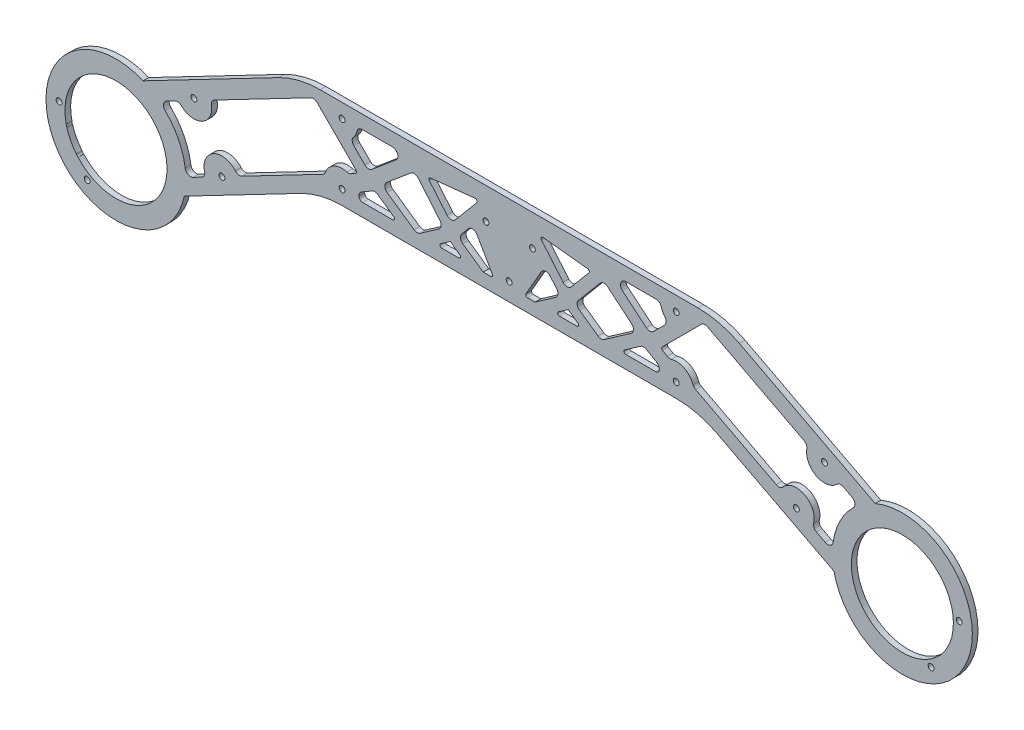
from build123d import *

# Parameters (mm, degrees)
BASE_DEPTH               = 3.175
FILLET1_R                = 10
SKETCH2_R                = 1.65
ADAPTER_ATTACHMENT_DEPTH = 4.175
SKETCH3_R                = 1.65
STRUT_HOLES_DEPTH        = 4.175
SKETCH4_R                = 16.05
SKETCH4_R_2              = 2.75
MOTOR_CONNECTION_DEPTH   = 4.175
SKETCH5_R                = 39.154759474
SKETCH5_R_2              = 28.55
SKETCH5_R_3              = 1.65
MOTOR_RING_DEPTH         = 3.175
MOTOR_SLOT_DEPTH         = 4.175
LIGHTENING_HOLES_DEPTH   = 4.175


with BuildPart() as part:
    # Sketch1 → Base (new body)
    with BuildSketch(Plane.XY):
        with BuildLine():
            Line((105.709062273, -33.213203436), (-105.709062273, -33.213203436))
            ThreePointArc((-105.709062273, -33.213203436), (-117.593356889, -34.646099945), (-128.796492935, -38.862661777))
            Line((-128.796492935, -38.862661777), (-262.589094492, -108.510681755))
            Line((-262.589094492, -108.510681755), (-239.50166383, -152.861223414))
            Line((-239.50166383, -152.861223414), (-116.561570773, -88.862661777))
            ThreePointArc((-116.561570773, -88.862661777), (-105.358434728, -84.646099945), (-93.474140111, -83.213203436))
            Line((-93.474140111, -83.213203436), (93.474140111, -83.213203436))
            ThreePointArc((93.474140111, -83.213203436), (105.358434728, -84.646099945), (116.561570773, -88.862661777))
            Line((116.561570773, -88.862661777), (239.50166383, -152.861223414))
            Line((239.50166383, -152.861223414), (262.589094492, -108.510681755))
            Line((262.589094492, -108.510681755), (128.796492935, -38.862661777))
            ThreePointArc((128.796492935, -38.862661777), (117.593356889, -34.646099945), (105.709062273, -33.213203436))
        make_face()
    extrude(amount=BASE_DEPTH)

    # Fillet1
    fillet1_edges = [part.edges().sort_by_distance(p)[0] for p in [
        (-262.589094492, -108.510681755, 1.5875),
        (262.589094492, -108.510681755, 1.5875),
        (239.50166383, -152.861223414, 1.5875),
        (-239.50166383, -152.861223414, 1.5875),
    ]]
    fillet(fillet1_edges, radius=FILLET1_R)

    # Sketch2 → Adapter Attachment (cut, through all)
    with BuildSketch(Plane.XY.offset(3.175)):
        with Locations((-12.990381057, -50.713203436)):
            Circle(SKETCH2_R)
        with Locations((12.990381057, -50.713203436)):
            Circle(SKETCH2_R)
        with Locations((0, -73.213203436)):
            Circle(SKETCH2_R)
    extrude(amount=-ADAPTER_ATTACHMENT_DEPTH, mode=Mode.SUBTRACT)

    # Sketch3 → Strut Holes (cut, through all)
    with BuildSketch(Plane.XY.offset(3.175)):
        with Locations((-251.799018921, -111.912779515)):
            Circle(SKETCH3_R)
        with Locations((-236.099566071, -142.071147843)):
            Circle(SKETCH3_R)
        with Locations((-160.703645251, -102.822515718)):
            Circle(SKETCH3_R)
        with Locations((-176.403098101, -72.66414739)):
            Circle(SKETCH3_R)
        with Locations((-93.474140111, -75.213203436)):
            Circle(SKETCH3_R)
        with Locations((-93.474140111, -41.213203436)):
            Circle(SKETCH3_R)
        with Locations((93.474140111, -41.213203436)):
            Circle(SKETCH3_R)
        with Locations((93.474140111, -75.213203436)):
            Circle(SKETCH3_R)
        with Locations((176.403098101, -72.66414739)):
            Circle(SKETCH3_R)
        with Locations((160.703645251, -102.822515718)):
            Circle(SKETCH3_R)
        with Locations((251.799018921, -111.912779515)):
            Circle(SKETCH3_R)
        with Locations((236.099566071, -142.071147843)):
            Circle(SKETCH3_R)
    extrude(amount=-STRUT_HOLES_DEPTH, mode=Mode.SUBTRACT)

    # Sketch4 → Motor Connection (cut, through all)
    with BuildSketch(Plane.XY.offset(3.175)):
        with Locations((-220, -114.524751121)):
            Circle(SKETCH4_R)
        with Locations((-241.458631392, -107.758870633)):
            Circle(SKETCH4_R_2)
        with Locations((-213.234119511, -93.06611973)):
            Circle(SKETCH4_R_2)
        with Locations((-198.541368608, -121.29063161)):
            Circle(SKETCH4_R_2)
        with Locations((-226.765880489, -135.983382513)):
            Circle(SKETCH4_R_2)
        with Locations((226.765880489, -135.983382513)):
            Circle(SKETCH4_R_2)
        with Locations((241.458631392, -107.758870633)):
            Circle(SKETCH4_R_2)
        with Locations((198.541368608, -121.29063161)):
            Circle(SKETCH4_R_2)
        with Locations((213.234119511, -93.06611973)):
            Circle(SKETCH4_R_2)
        with Locations((220, -114.524751121)):
            Circle(SKETCH4_R)
    extrude(amount=-MOTOR_CONNECTION_DEPTH, mode=Mode.SUBTRACT)

    # Sketch5 → Motor Ring (add)
    with BuildSketch(Plane.XY.offset(3.175)):
        with Locations((-220, -114.524751121)):
            Circle(SKETCH5_R)
        with Locations((-220, -114.524751121)):
            Circle(SKETCH5_R_2, mode=Mode.SUBTRACT)
        with Locations((-236.099566071, -142.071147843)):
            Circle(SKETCH5_R_3, mode=Mode.SUBTRACT)
        with Locations((-251.799018921, -111.912779515)):
            Circle(SKETCH5_R_3, mode=Mode.SUBTRACT)
        with Locations((220, -114.524751121)):
            Circle(SKETCH5_R)
        with Locations((251.799018921, -111.912779515)):
            Circle(SKETCH5_R_3, mode=Mode.SUBTRACT)
        with Locations((236.099566071, -142.071147843)):
            Circle(SKETCH5_R_3, mode=Mode.SUBTRACT)
        with Locations((220, -114.524751121)):
            Circle(SKETCH5_R_2, mode=Mode.SUBTRACT)
    extrude(amount=-MOTOR_RING_DEPTH)

    # Sketch5_2 → Motor Slot (cut, through all)
    with BuildSketch(Plane.XY.offset(3.175)):
        with BuildLine():
            ThreePointArc((-196.226386581, -130.333539975), (-192.670170481, -122.782045984), (-191.45, -114.524751121))
            ThreePointArc((-191.45, -114.524751121), (-199.570939599, -94.580930245), (-219.313817243, -85.982998316))
            Line((-219.313817243, -85.982998316), (-243.773613419, -98.715962268))
            ThreePointArc((-243.773613419, -98.715962268), (-245.324159287, -127.707674029), (-220.686182757, -143.066503927))
            Line((-220.686182757, -143.066503927), (-196.226386581, -130.333539975))
        make_face()
        with BuildLine():
            Line((243.773613419, -98.715962268), (219.313817243, -85.982998316))
            ThreePointArc((219.313817243, -85.982998316), (194.675840713, -101.341828214), (196.226386581, -130.333539975))
            Line((196.226386581, -130.333539975), (220.686182757, -143.066503927))
            ThreePointArc((220.686182757, -143.066503927), (240.429060401, -134.468571998), (248.55, -114.524751121))
            ThreePointArc((248.55, -114.524751121), (247.329829519, -106.267456259), (243.773613419, -98.715962268))
        make_face()
    extrude(amount=-MOTOR_SLOT_DEPTH, mode=Mode.SUBTRACT)

    # Sketch6 → Lightening Holes (cut, through all)
    with BuildSketch(Plane.XY.offset(3.175)):
        with BuildLine():
            Line((-247.606795008, -122.131647293), (-242.06581165, -132.775777291))
            ThreePointArc((-242.06581165, -132.775777291), (-240.893201582, -133.759713966), (-239.368292757, -133.626301731))
            Line((-239.368292757, -133.626301731), (-237.59427109, -132.702804504))
            ThreePointArc((-237.59427109, -132.702804504), (-236.610334415, -131.530194437), (-236.743746651, -130.005285612))
            Line((-236.743746651, -130.005285612), (-242.284730009, -119.361155613))
            ThreePointArc((-242.284730009, -119.361155613), (-243.457340077, -118.377218938), (-244.982248902, -118.510631174))
            Line((-244.982248902, -118.510631174), (-246.756270569, -119.4341284))
            ThreePointArc((-246.756270569, -119.4341284), (-247.740207244, -120.606738467), (-247.606795008, -122.131647293))
        make_face()
        with BuildLine():
            Line((-14.539319226, -75.963203436), (-10.271370034, -75.963203436))
            ThreePointArc((-10.271370034, -75.963203436), (-9.40534463, -75.463203436), (-9.40534463, -74.463203436))
            Line((-9.40534463, -74.463203436), (-17.992546949, -59.589732725))
            ThreePointArc((-17.992546949, -59.589732725), (-20.329155932, -58.10114863), (-22.88875649, -59.161369895))
            Line((-22.88875649, -59.161369895), (-26.574867267, -63.554305657))
            ThreePointArc((-26.574867267, -63.554305657), (-27.251068522, -65.874247063), (-25.997463246, -67.940124619))
            Line((-25.997463246, -67.940124619), (-14.539319226, -75.963203436))
        make_face()
        with BuildLine():
            Line((-28.171594802, -75.963203436), (-37.828405198, -75.963203436))
            ThreePointArc((-37.828405198, -75.963203436), (-38.782122148, -75.263909235), (-38.401981634, -74.144051391))
            Line((-38.401981634, -74.144051391), (-33, -70.36154313))
            Line((-33, -70.36154313), (-27.598018366, -74.144051391))
            ThreePointArc((-27.598018366, -74.144051391), (-27.217877852, -75.263909235), (-28.171594802, -75.963203436))
        make_face()
        with BuildLine():
            Line((-18.961528069, -42.471920461), (-43.967972264, -45.100203655))
            ThreePointArc((-43.967972264, -45.100203655), (-44.790627656, -45.720118957), (-44.629488244, -46.73751316))
            Line((-44.629488244, -46.73751316), (-34.761050762, -58.498258983))
            ThreePointArc((-34.761050762, -58.498258983), (-32.462917433, -59.569896154), (-30.164784103, -58.498258983))
            Line((-30.164784103, -58.498258983), (-18.090955162, -44.109229966))
            ThreePointArc((-18.090955162, -44.109229966), (-17.974052013, -42.996970793), (-18.961528069, -42.471920461))
        make_face()
        with BuildLine():
            Line((-50.875469734, -48.628185241), (-38.748511984, -63.080530707))
            ThreePointArc((-38.748511984, -63.080530707), (-38.072310729, -65.400472113), (-39.325916004, -67.466349669))
            Line((-39.325916004, -67.466349669), (-49.779270691, -74.785867421))
            ThreePointArc((-49.779270691, -74.785867421), (-51.5, -75.328411288), (-53.220729309, -74.785867421))
            Line((-53.220729309, -74.785867421), (-68.276972398, -64.243372513))
            ThreePointArc((-68.276972398, -64.243372513), (-69.553387753, -61.916774542), (-68.484605918, -59.487783051))
            Line((-68.484605918, -59.487783051), (-55.101965892, -48.258414741))
            ThreePointArc((-55.101965892, -48.258414741), (-52.912135835, -47.567963976), (-50.875469734, -48.628185241))
        make_face()
        with BuildLine():
            Line((-64.598018366, -74.144051391), (-73.50757862, -67.905510139))
            ThreePointArc((-73.50757862, -67.905510139), (-75.097449767, -67.365821608), (-76.728307929, -67.764890061))
            Line((-76.728307929, -67.764890061), (-82.5, -71.097178032))
            ThreePointArc((-82.5, -71.097178032), (-83.598076211, -72.195254243), (-84, -73.695254243))
            Line((-84, -73.695254243), (-84, -73.963203436))
            ThreePointArc((-84, -73.963203436), (-83.414213562, -75.377416998), (-82, -75.963203436))
            Line((-82, -75.963203436), (-65.171594802, -75.963203436))
            ThreePointArc((-65.171594802, -75.963203436), (-64.217877852, -75.263909235), (-64.598018366, -74.144051391))
        make_face()
        with BuildLine():
            Line((-65.242432258, -40.713203436), (-82.249167951, -40.713203436))
            ThreePointArc((-82.249167951, -40.713203436), (-84.125797678, -41.372634943), (-85.177421558, -43.061029523))
            ThreePointArc((-85.177421558, -43.061029523), (-85.893893432, -45.058962175), (-87.083022993, -46.817096902))
            ThreePointArc((-87.083022993, -46.817096902), (-87.825724166, -48.893226977), (-86.948654942, -50.916261998))
            Line((-86.948654942, -50.916261998), (-80.77609859, -57.088818351))
            ThreePointArc((-80.77609859, -57.088818351), (-78.785636408, -57.964642672), (-76.726415417, -57.265631337))
            Line((-76.726415417, -57.265631337), (-63.314069429, -46.011336765))
            ThreePointArc((-63.314069429, -46.011336765), (-62.423354396, -42.687143006), (-65.242432258, -40.713203436))
        make_face()
        with BuildLine():
            Line((-107.484512436, -40.279899441), (-85.580100391, -62.184311486))
            ThreePointArc((-85.580100391, -62.184311486), (-85.295762311, -63.021944459), (-85.787207173, -63.757443671))
            Line((-85.787207173, -63.757443671), (-88.453797468, -65.297000296))
            ThreePointArc((-88.453797468, -65.297000296), (-89.580696964, -65.675633008), (-90.766184232, -65.586834704))
            ThreePointArc((-90.766184232, -65.586834704), (-98.052239386, -66.322702492), (-102.883146832, -71.826377114))
            ThreePointArc((-102.883146832, -71.826377114), (-103.446822537, -72.784360657), (-104.320603008, -73.471361716))
            Line((-104.320603008, -73.471361716), (-149.483747082, -96.981806421))
            ThreePointArc((-149.483747082, -96.981806421), (-151.43261898, -97.267352559), (-153.138528075, -96.282714336))
            ThreePointArc((-153.138528075, -96.282714336), (-165.321131383, -93.952407386), (-170.399909872, -105.268420947))
            ThreePointArc((-170.399909872, -105.268420947), (-170.571810718, -107.230585152), (-171.923543419, -108.663225015))
            Line((-171.923543419, -108.663225015), (-176.885345383, -111.246175629))
            ThreePointArc((-176.885345383, -111.246175629), (-179.641865148, -111.253402453), (-181.240655904, -109.007891029))
            ThreePointArc((-181.240655904, -109.007891029), (-185.049879924, -96.883560496), (-192.541948791, -86.618158284))
            ThreePointArc((-192.541948791, -86.618158284), (-193.404792386, -84.03536629), (-191.823129404, -81.818689552))
            Line((-191.823129404, -81.818689552), (-186.913067556, -79.262673137))
            ThreePointArc((-186.913067556, -79.262673137), (-185.082327719, -78.956967513), (-183.422116267, -79.786884503))
            ThreePointArc((-183.422116267, -79.786884503), (-171.785611968, -81.534255722), (-166.542550007, -70.999938481))
            ThreePointArc((-166.542550007, -70.999938481), (-166.270120038, -69.163952045), (-164.969631419, -67.839643308))
            Line((-164.969631419, -67.839643308), (-110.99107862, -39.740187285))
            ThreePointArc((-110.99107862, -39.740187285), (-109.149462621, -39.436135253), (-107.484512436, -40.279899441))
        make_face()
        with BuildLine():
            Line((149.483747082, -96.981806421), (104.320603008, -73.471361716))
            ThreePointArc((104.320603008, -73.471361716), (103.446822537, -72.784360657), (102.883146832, -71.826377114))
            ThreePointArc((102.883146832, -71.826377114), (98.052239386, -66.322702492), (90.766184232, -65.586834704))
            ThreePointArc((90.766184232, -65.586834704), (89.580696964, -65.675633008), (88.453797468, -65.297000296))
            Line((88.453797468, -65.297000296), (85.787207173, -63.757443671))
            ThreePointArc((85.787207173, -63.757443671), (85.295762311, -63.021944459), (85.580100391, -62.184311486))
            Line((85.580100391, -62.184311486), (107.484512436, -40.279899441))
            ThreePointArc((107.484512436, -40.279899441), (109.149462621, -39.436135253), (110.99107862, -39.740187285))
            Line((110.99107862, -39.740187285), (164.969631419, -67.839643308))
            ThreePointArc((164.969631419, -67.839643308), (166.270120038, -69.163952045), (166.542550007, -70.999938481))
            ThreePointArc((166.542550007, -70.999938481), (171.785611968, -81.534255722), (183.422116267, -79.786884503))
            ThreePointArc((183.422116267, -79.786884503), (185.082327719, -78.956967513), (186.913067556, -79.262673137))
            Line((186.913067556, -79.262673137), (191.823129404, -81.818689552))
            ThreePointArc((191.823129404, -81.818689552), (193.404792386, -84.03536629), (192.541948791, -86.618158284))
            ThreePointArc((192.541948791, -86.618158284), (185.049879924, -96.883560496), (181.240655904, -109.007891029))
            ThreePointArc((181.240655904, -109.007891029), (179.641865148, -111.253402453), (176.885345383, -111.246175629))
            Line((176.885345383, -111.246175629), (171.923543419, -108.663225015))
            ThreePointArc((171.923543419, -108.663225015), (170.571810718, -107.230585152), (170.399909872, -105.268420947))
            ThreePointArc((170.399909872, -105.268420947), (165.321131383, -93.952407386), (153.138528075, -96.282714336))
            ThreePointArc((153.138528075, -96.282714336), (151.43261898, -97.267352559), (149.483747082, -96.981806421))
        make_face()
        with BuildLine():
            Line((76.726415417, -57.265631337), (63.314069429, -46.011336765))
            ThreePointArc((63.314069429, -46.011336765), (62.423354396, -42.687143006), (65.242432258, -40.713203436))
            Line((65.242432258, -40.713203436), (82.249167951, -40.713203436))
            ThreePointArc((82.249167951, -40.713203436), (84.125797678, -41.372634943), (85.177421558, -43.061029523))
            ThreePointArc((85.177421558, -43.061029523), (85.893893432, -45.058962175), (87.083022993, -46.817096902))
            ThreePointArc((87.083022993, -46.817096902), (87.825724166, -48.893226977), (86.948654942, -50.916261998))
            Line((86.948654942, -50.916261998), (80.77609859, -57.088818351))
            ThreePointArc((80.77609859, -57.088818351), (78.785636408, -57.964642672), (76.726415417, -57.265631337))
        make_face()
        with BuildLine():
            Line((82, -75.963203436), (65.171594802, -75.963203436))
            ThreePointArc((65.171594802, -75.963203436), (64.217877852, -75.263909235), (64.598018366, -74.144051391))
            Line((64.598018366, -74.144051391), (73.50757862, -67.905510139))
            ThreePointArc((73.50757862, -67.905510139), (75.097449767, -67.365821608), (76.728307929, -67.764890061))
            Line((76.728307929, -67.764890061), (82.5, -71.097178032))
            ThreePointArc((82.5, -71.097178032), (83.598076211, -72.195254243), (84, -73.695254243))
            Line((84, -73.695254243), (84, -73.963203436))
            ThreePointArc((84, -73.963203436), (83.414213562, -75.377416998), (82, -75.963203436))
        make_face()
        with BuildLine():
            Line((9.40534463, -74.463203436), (17.992546949, -59.589732725))
            ThreePointArc((17.992546949, -59.589732725), (20.329155932, -58.10114863), (22.88875649, -59.161369895))
            Line((22.88875649, -59.161369895), (26.574867267, -63.554305657))
            ThreePointArc((26.574867267, -63.554305657), (27.251068522, -65.874247063), (25.997463246, -67.940124619))
            Line((25.997463246, -67.940124619), (14.539319226, -75.963203436))
            Line((14.539319226, -75.963203436), (10.271370034, -75.963203436))
            ThreePointArc((10.271370034, -75.963203436), (9.40534463, -75.463203436), (9.40534463, -74.463203436))
        make_face()
        with BuildLine():
            Line((68.484605918, -59.487783051), (55.101965892, -48.258414741))
            ThreePointArc((55.101965892, -48.258414741), (52.912135835, -47.567963976), (50.875469734, -48.628185241))
            Line((50.875469734, -48.628185241), (38.748511984, -63.080530707))
            ThreePointArc((38.748511984, -63.080530707), (38.072310729, -65.400472113), (39.325916004, -67.466349669))
            Line((39.325916004, -67.466349669), (49.779270691, -74.785867421))
            ThreePointArc((49.779270691, -74.785867421), (51.5, -75.328411288), (53.220729309, -74.785867421))
            Line((53.220729309, -74.785867421), (68.276972398, -64.243372513))
            ThreePointArc((68.276972398, -64.243372513), (69.553387753, -61.916774542), (68.484605918, -59.487783051))
        make_face()
        with BuildLine():
            Line((30.164784103, -58.498258983), (18.090955162, -44.109229966))
            ThreePointArc((18.090955162, -44.109229966), (17.974052013, -42.996970793), (18.961528069, -42.471920461))
            Line((18.961528069, -42.471920461), (43.967972264, -45.100203655))
            ThreePointArc((43.967972264, -45.100203655), (44.790627656, -45.720118957), (44.629488244, -46.73751316))
            Line((44.629488244, -46.73751316), (34.761050762, -58.498258983))
            ThreePointArc((34.761050762, -58.498258983), (32.462917433, -59.569896154), (30.164784103, -58.498258983))
        make_face()
        with BuildLine():
            Line((33, -70.36154313), (27.598018366, -74.144051391))
            ThreePointArc((27.598018366, -74.144051391), (27.217877852, -75.263909235), (28.171594802, -75.963203436))
            Line((28.171594802, -75.963203436), (37.828405198, -75.963203436))
            ThreePointArc((37.828405198, -75.963203436), (38.782122148, -75.263909235), (38.401981634, -74.144051391))
            Line((38.401981634, -74.144051391), (33, -70.36154313))
        make_face()
        with BuildLine():
            Line((244.982248902, -118.510631174), (246.756270569, -119.4341284))
            ThreePointArc((246.756270569, -119.4341284), (247.740207244, -120.606738467), (247.606795008, -122.131647293))
            Line((247.606795008, -122.131647293), (242.06581165, -132.775777291))
            ThreePointArc((242.06581165, -132.775777291), (240.893201582, -133.759713966), (239.368292757, -133.626301731))
            Line((239.368292757, -133.626301731), (237.59427109, -132.702804504))
            ThreePointArc((237.59427109, -132.702804504), (236.610334415, -131.530194437), (236.743746651, -130.005285612))
            Line((236.743746651, -130.005285612), (242.284730009, -119.361155613))
            ThreePointArc((242.284730009, -119.361155613), (243.457340077, -118.377218938), (244.982248902, -118.510631174))
        make_face()
    extrude(amount=-LIGHTENING_HOLES_DEPTH, mode=Mode.SUBTRACT)


solid = part.part
